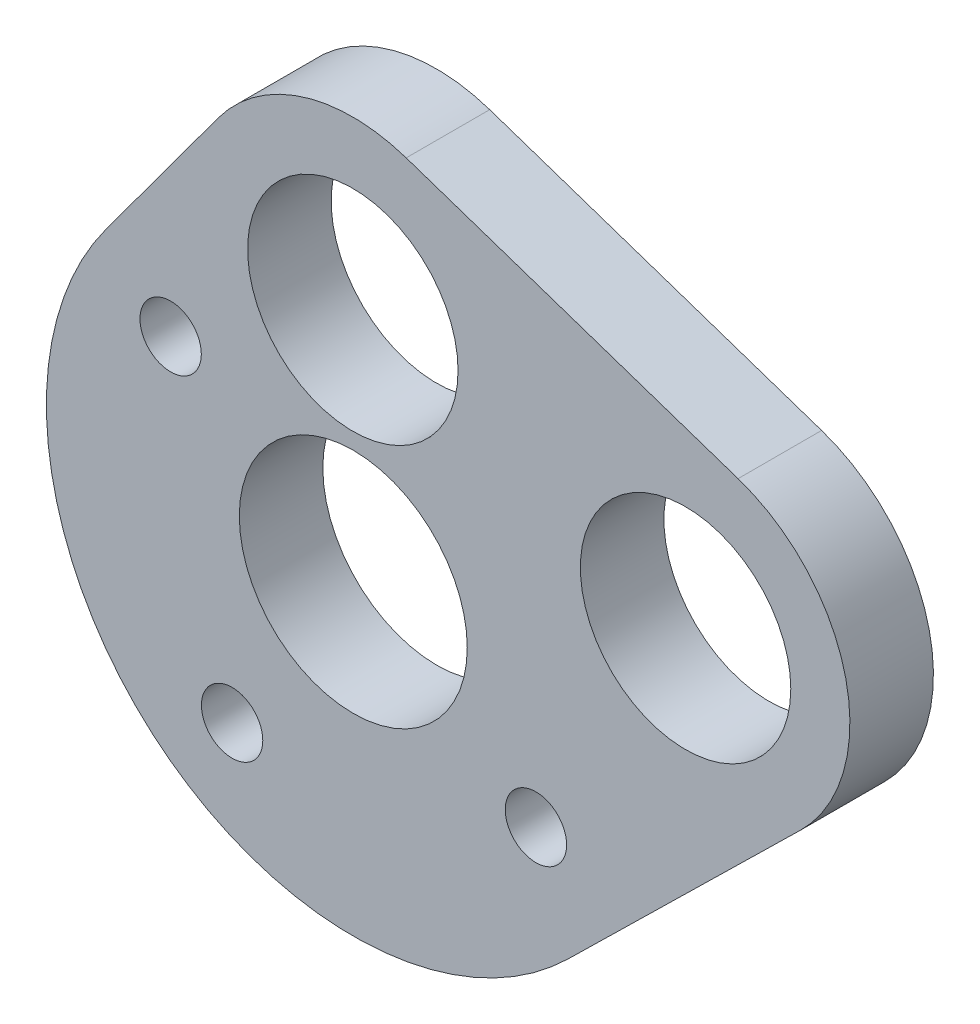
from build123d import *

# Parameters (mm, degrees)
SKETCH1_R           = 6
SKETCH1_R_2         = 6.5
SKETCH1_R_3         = 1.75
BOSS_EXTRUDE1_DEPTH = 4.7625


with BuildPart() as part:
    # Sketch1 → Boss-Extrude1 (new body)
    with BuildSketch(Plane.XY):
        with BuildLine():
            Line((3.017307004, 21.853032868), (21.943018301, 15.473699222))
            ThreePointArc((21.943018301, 15.473699222), (28.085108949, 8.684008391), (25.508449632, -0.101548271))
            Line((25.508449632, -0.101548271), (12.247407267, -13.094576991))
            ThreePointArc((12.247407267, -13.094576991), (-11.473284724, -13.808685528), (-14.095077044, 9.777483822))
            Line((-14.095077044, 9.777483822), (-7.696868023, 18.472342425))
            ThreePointArc((-7.696868023, 18.472342425), (-2.891288013, 21.910540052), (3.017307004, 21.853032868))
        make_face()
        with Locations((-0.025118946, 12.827)):
            Circle(SKETCH1_R, mode=Mode.SUBTRACT)
        with Locations((18.949483523, 6.592712883)):
            Circle(SKETCH1_R, mode=Mode.SUBTRACT)
        with Locations((0, -0.594536382)):
            Circle(SKETCH1_R_2, mode=Mode.SUBTRACT)
        with Locations((-10.415933459, 6.316203823)):
            Circle(SKETCH1_R_3, mode=Mode.SUBTRACT)
        with Locations((-6.910740205, -11.010469841)):
            Circle(SKETCH1_R_3, mode=Mode.SUBTRACT)
        with Locations((10.415933459, -7.505276587)):
            Circle(SKETCH1_R_3, mode=Mode.SUBTRACT)
    extrude(amount=BOSS_EXTRUDE1_DEPTH)


solid = part.part
